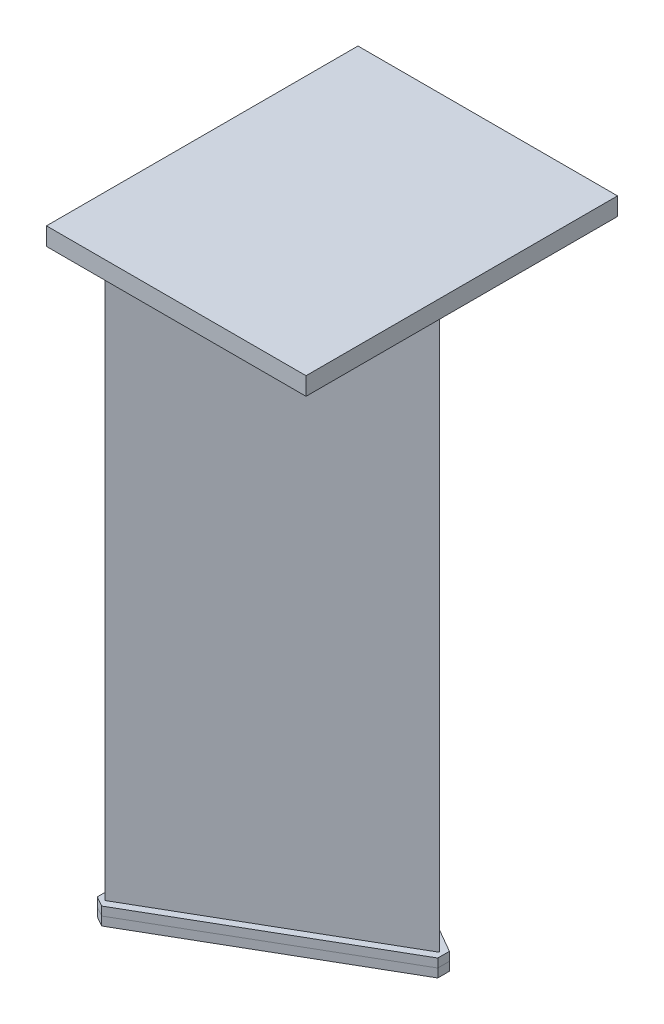
from build123d import *

# Parameters (mm, degrees)
BASE_GROUT_DEPTH = 25.4
TABLE_START      = 1752.6
SKETCH33_W       = 762
SKETCH33_H       = 914.4
TABLE_DEPTH      = 52.451
PIER_BODY_DEPTH  = 1674.749
LHO_1_LIFT_DEPTH = 25.4


with BuildPart() as part:
    # Sketch31 → Base & Grout (new body)
    with BuildSketch(Plane(origin=(0, 0, 0), x_dir=(1, 0, 0), z_dir=(0, 1, 0))):
        Polygon((-228.261333333, 361.222626737), (-228.261333333, -361.222626737), (-198.697304509, -378.291426737), (426.958637842, -17.0688), (426.958637842, 17.0688), (-198.697304509, 378.291426737), align=None)
    extrude(amount=BASE_GROUT_DEPTH)


with BuildPart() as body_2:
    # Sketch33 → Table (new body)
    with BuildSketch(Plane(origin=(0, 0, 0), x_dir=(1, 0, 0), z_dir=(0, 1, 0)).offset(TABLE_START)):
        with Locations((99.348652255, 0)):
            Rectangle(SKETCH33_W, SKETCH33_H)
    extrude(amount=-TABLE_DEPTH)


with BuildPart() as body_3:
    # Sketch1 → Pier Body (new body)
    with BuildSketch(Plane(origin=(0, 25.4, -25.4), x_dir=(1, 0, 0), z_dir=(0, -1, 0))):
        Polygon((414.866666667, 25.4), (-207.433333333, 384.685072517), (-207.433333333, -333.885072517), align=None)
    extrude(amount=-PIER_BODY_DEPTH)


with BuildPart() as body_4:
    # Sketch32 → LHO 1" Lift (new body)
    with BuildSketch(Plane(origin=(0, 0, 0), x_dir=(-1, 0, 0), z_dir=(0, -1, 0))):
        Polygon((228.261333333, 361.222626737), (198.697304509, 378.291426737), (-426.958637842, 17.0688), (-426.958637842, -17.0688), (198.697304509, -378.291426737), (228.261333333, -361.222626737), align=None)
    extrude(amount=LHO_1_LIFT_DEPTH)


solid = Compound([part.part, body_2.part, body_3.part, body_4.part])
